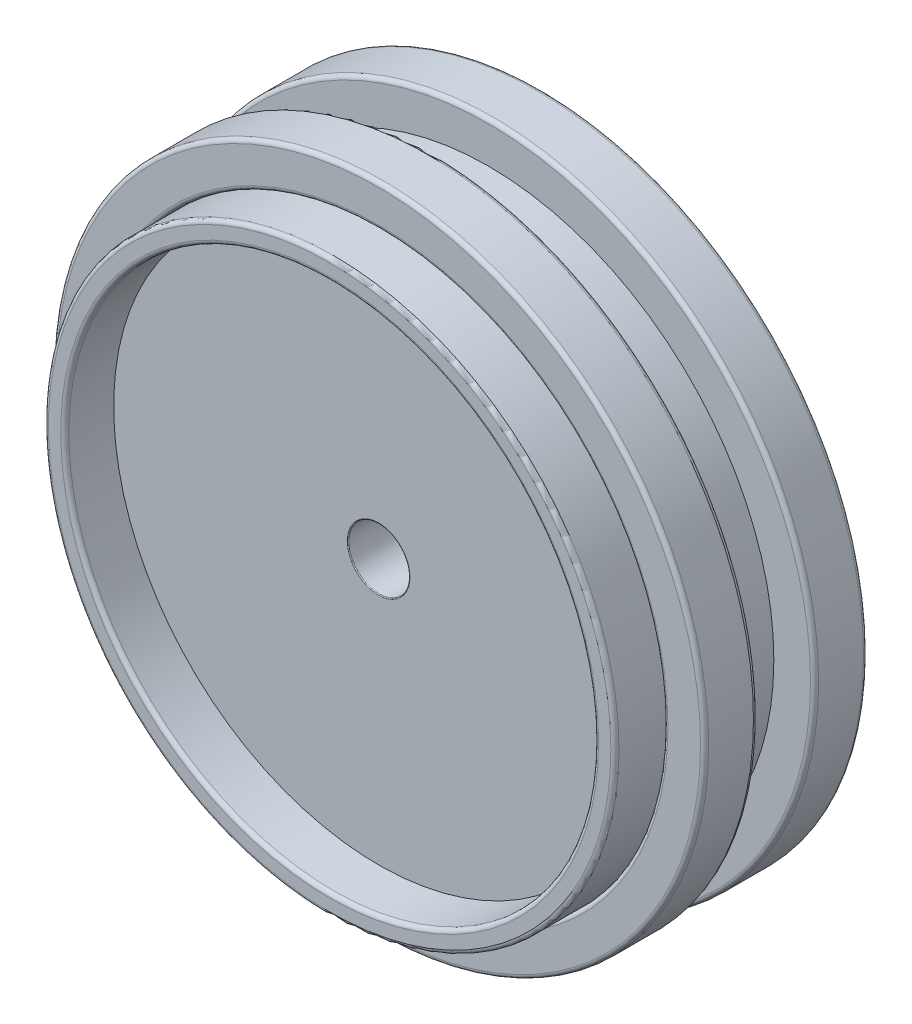
from build123d import *

# Parameters (mm, degrees)
BOSS_EXTRUDE1_DEPTH      = 15.24
BOSS_EXTRUDE1_DEPTH_BACK = 50.8
SKETCH1_R                = 88.9
SKETCH1_R_2              = 82.55
SKETCH1_3_R              = 101.6
SKETCH1_3_R_2            = 88.9
BOSS_EXTRUDE2_DEPTH      = 50.8
SKETCH1_4_R              = 82.55
BOSS_EXTRUDE3_DEPTH      = 31.75
SKETCH4_W                = 12.7
SKETCH4_H                = 17.78
SKETCH5_R                = 9.525
CUT_EXTRUDE1_DEPTH       = 44.45
FILLET1_R                = 1.27
FILLET2_R                = 1.27
FILLET6_R                = 1.27
FILLET9_R                = 0.254


with BuildPart() as part:
    # Sketch1 → Boss-Extrude1 (new, two sides: drawn at the far end of the back side and taken through both)
    with BuildSketch(Plane.XY.offset(-BOSS_EXTRUDE1_DEPTH_BACK)):
        Circle(SKETCH1_R)
        Circle(SKETCH1_R_2, mode=Mode.SUBTRACT)
    extrude(amount=BOSS_EXTRUDE1_DEPTH + BOSS_EXTRUDE1_DEPTH_BACK)

    # Fillet2
    fillet2_edges = [part.edges().sort_by_distance(p)[0] for p in [
        (-82.55, 0, -50.8),
        (-82.55, 0, 15.24),
        (-88.9, 0, 15.24),
    ]]
    fillet(fillet2_edges, radius=FILLET2_R)


with BuildPart() as body_2:
    # Sketch1_3 → Boss-Extrude2 (new body)
    with BuildSketch(Plane.XY):
        Circle(SKETCH1_3_R)
        Circle(SKETCH1_3_R_2, mode=Mode.SUBTRACT)
    extrude(amount=-BOSS_EXTRUDE2_DEPTH)

    # Sketch4 → Cut-Revolve1 (revolve, cut)
    with BuildSketch(Plane(origin=(0, 0, 0), x_dir=(1, 0, 0), z_dir=(0, 1, 0))):
        with Locations((95.25, 25.4)):
            Rectangle(SKETCH4_W, SKETCH4_H)
    revolve(axis=Axis((0, 0, 0), (0, 0, 1)), mode=Mode.SUBTRACT)


with BuildPart() as body_3:
    # Sketch1_4 → Boss-Extrude3 (new body)
    with BuildSketch(Plane.XY):
        Circle(SKETCH1_4_R)
    extrude(amount=-BOSS_EXTRUDE3_DEPTH)

    # Sketch5 → Cut-Extrude1 (cut)
    with BuildSketch(Plane.XY):
        Circle(SKETCH5_R)
    extrude(amount=-CUT_EXTRUDE1_DEPTH, mode=Mode.SUBTRACT)

    # Fillet9
    fillet9_edges = [body_3.edges().sort_by_distance(p)[0] for p in [
        (-9.525, 0, -31.75),
        (-9.525, 0, 0),
    ]]
    fillet(fillet9_edges, radius=FILLET9_R)


with BuildPart() as cut_revolve1_piece_1:
    # of the separate pieces the step leaves, piece 1, a body of its own (cut_revolve1_pieces)
    add(body_2.part.solids().sort_by_distance((101.6, 0, 0))[0])

    # Fillet1
    fillet1_edges = [cut_revolve1_piece_1.edges().sort_by_distance(p)[0] for p in [
        (-88.9, 0, 0),
        (-101.6, 0, -16.51),
        (-101.6, 0, 0),
    ]]
    fillet(fillet1_edges, radius=FILLET1_R)


with BuildPart() as cut_revolve1_piece_2:
    # of the separate pieces the step leaves, piece 2, a body of its own (cut_revolve1_pieces)
    add(body_2.part.solids().sort_by_distance((101.6, 0, -34.29))[0])

    # Fillet6
    fillet6_edges = [cut_revolve1_piece_2.edges().sort_by_distance(p)[0] for p in [
        (-101.6, 0, -50.8),
        (-101.6, 0, -34.29),
    ]]
    fillet(fillet6_edges, radius=FILLET6_R)


solid = Compound([part.part, body_3.part, cut_revolve1_piece_1.part, cut_revolve1_piece_2.part])
